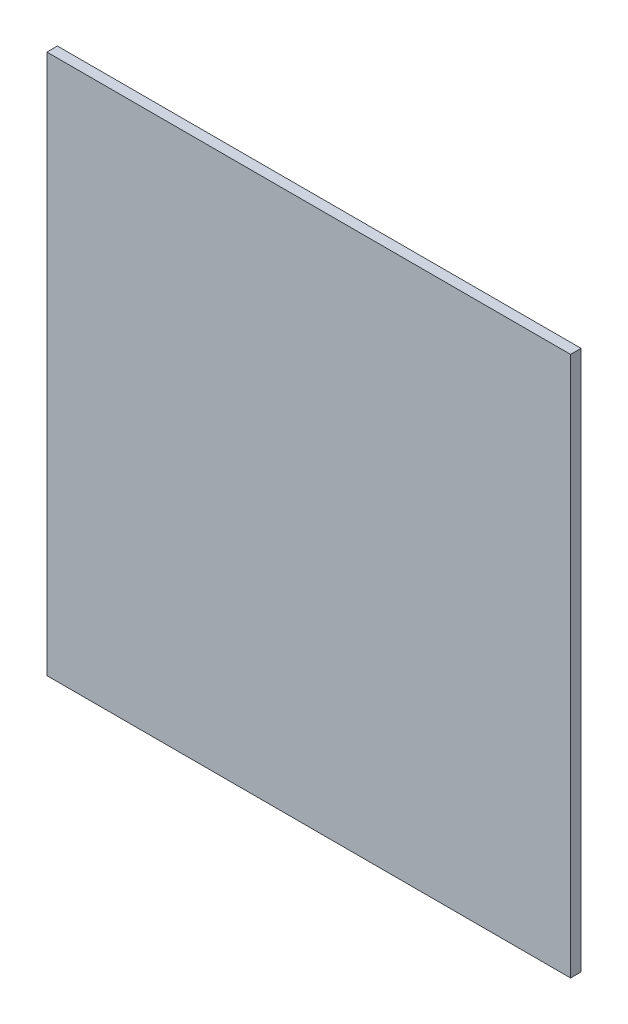
from build123d import *

# Parameters (mm, degrees)
SKETCH1_W           = 249.6
SKETCH1_H           = 257.4
BOSS_EXTRUDE1_DEPTH = 5


with BuildPart() as part:
    # Sketch1 → Boss-Extrude1 (new body)
    with BuildSketch(Plane.XY):
        with Locations((124.8, -128.7)):
            Rectangle(SKETCH1_W, SKETCH1_H)
    extrude(amount=BOSS_EXTRUDE1_DEPTH)


solid = part.part
